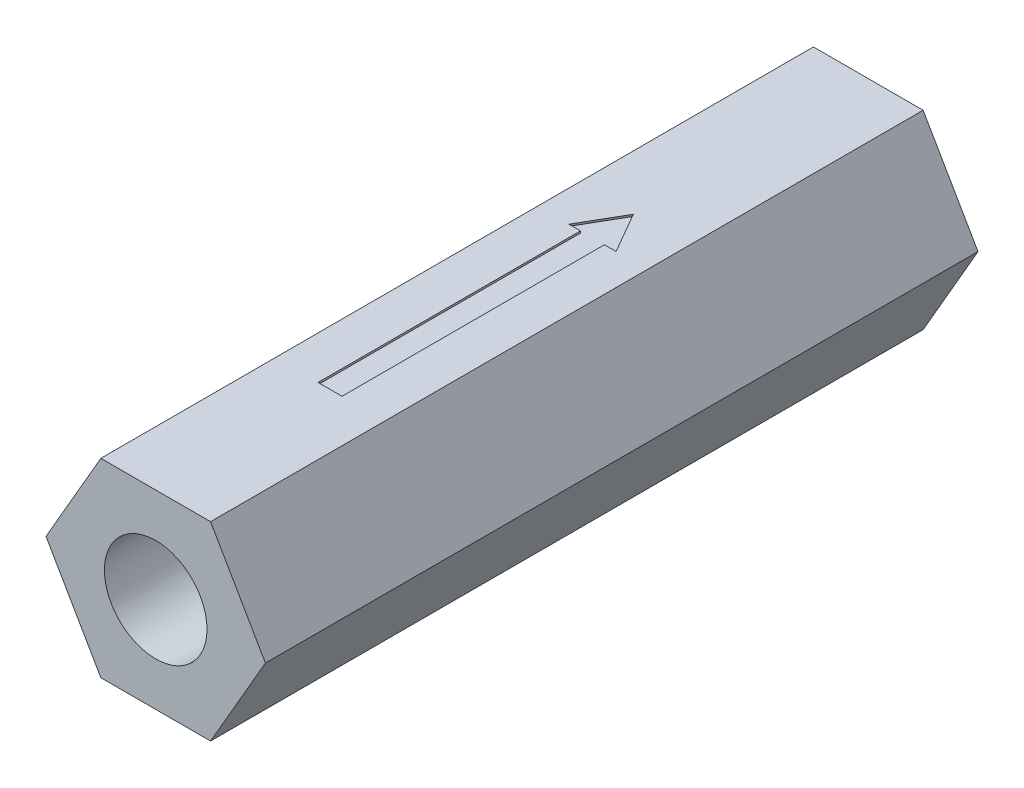
from build123d import *

# Parameters (mm, degrees)
BOSS_EXTRUDE1_DEPTH = 95.25
SKETCH2_R           = 6.858
CUT_EXTRUDE1_DEPTH  = 17.145
SKETCH3_R           = 6.858
CUT_EXTRUDE2_DEPTH  = 17.145
CUT_EXTRUDE3_DEPTH  = 0.254


with BuildPart() as part:
    # Sketch1 → Boss-Extrude1 (new body)
    with BuildSketch(Plane.XY):
        Polygon((14.664696837, 0), (7.332348419, 12.7), (-7.332348419, 12.7), (-14.664696837, 0), (-7.332348419, -12.7), (7.332348419, -12.7), align=None)
    extrude(amount=BOSS_EXTRUDE1_DEPTH)

    # Sketch2 → Cut-Extrude1 (cut)
    with BuildSketch(Plane.XY.offset(95.25)):
        Circle(SKETCH2_R)
    extrude(amount=-CUT_EXTRUDE1_DEPTH, mode=Mode.SUBTRACT)

    # Sketch3 → Cut-Extrude2 (cut)
    with BuildSketch(Plane(origin=(0, 0, 0), x_dir=(-1, 0, 0), z_dir=(0, 0, -1))):
        Circle(SKETCH3_R)
    extrude(amount=-CUT_EXTRUDE2_DEPTH, mode=Mode.SUBTRACT)

    # Sketch5 → Cut-Extrude3 (cut)
    with BuildSketch(Plane(origin=(0, 12.7, 0), x_dir=(1, 0, 0), z_dir=(0, 1, 0))):
        Polygon((-1.600451542, -71.949067171), (1.600451542, -71.949067171), (1.600451542, -36.866567036), (3.153270171, -36.866567036), (0, -31.40494289), (-3.153270171, -36.866567036), (-1.600451542, -36.866567036), (-1.600451542, -42.196329226), align=None)
    extrude(amount=-CUT_EXTRUDE3_DEPTH, mode=Mode.SUBTRACT)


solid = part.part
